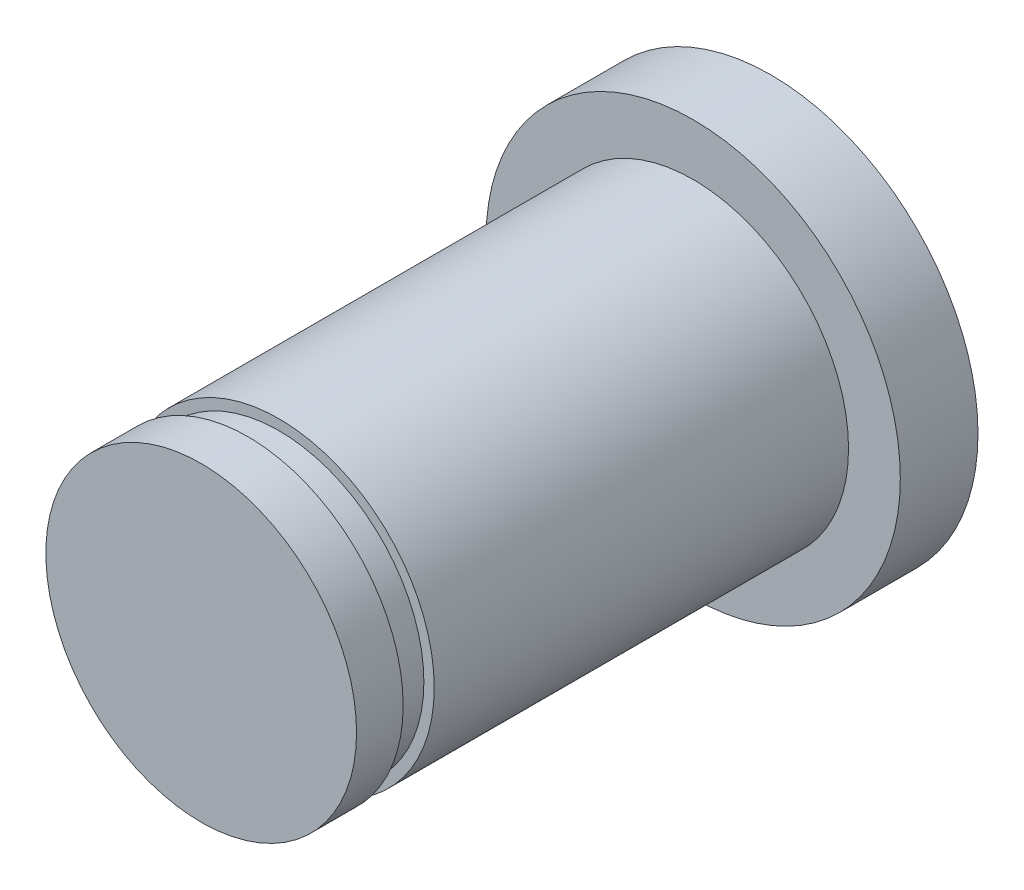
from build123d import *

# Parameters (mm, degrees)
SKETCH_1_R           = 4
EXTRUDE_1_DEPTH      = 1.5
SKETCH_1_3_R         = 3
EXTRUDE_2_DEPTH      = 11
CUT_EXTRUDE_START    = 10.1
SKETCH_1_4_OUTSIDE_W = 13.156
SKETCH_1_4_OUTSIDE_H = 13.156
SKETCH_1_4_OUTSIDE_R = 2.8
CUT_EXTRUDE_1_DEPTH  = 0.6


with BuildPart() as part:
    # 草图1 → 凸台-拉伸1 (new body)
    with BuildSketch(Plane.XY):
        with Locations((0.365715483, 0.182857742)):
            Circle(SKETCH_1_R)
    extrude(amount=EXTRUDE_1_DEPTH)

    # 草图1<3> → 凸台-拉伸2 (add)
    with BuildSketch(Plane.XY):
        with Locations((0.365715483, 0.182857742)):
            Circle(SKETCH_1_3_R)
    extrude(amount=EXTRUDE_2_DEPTH)

    # 草图1<4> outside → 切除-拉伸1 (cut)
    with BuildSketch(Plane.XY.offset(CUT_EXTRUDE_START)):
        with Locations((0.366, 0.183)):
            Rectangle(SKETCH_1_4_OUTSIDE_W, SKETCH_1_4_OUTSIDE_H)
        with Locations((0.365715483, 0.182857742)):
            Circle(SKETCH_1_4_OUTSIDE_R, mode=Mode.SUBTRACT)
    extrude(amount=-CUT_EXTRUDE_1_DEPTH, mode=Mode.SUBTRACT)


solid = part.part
